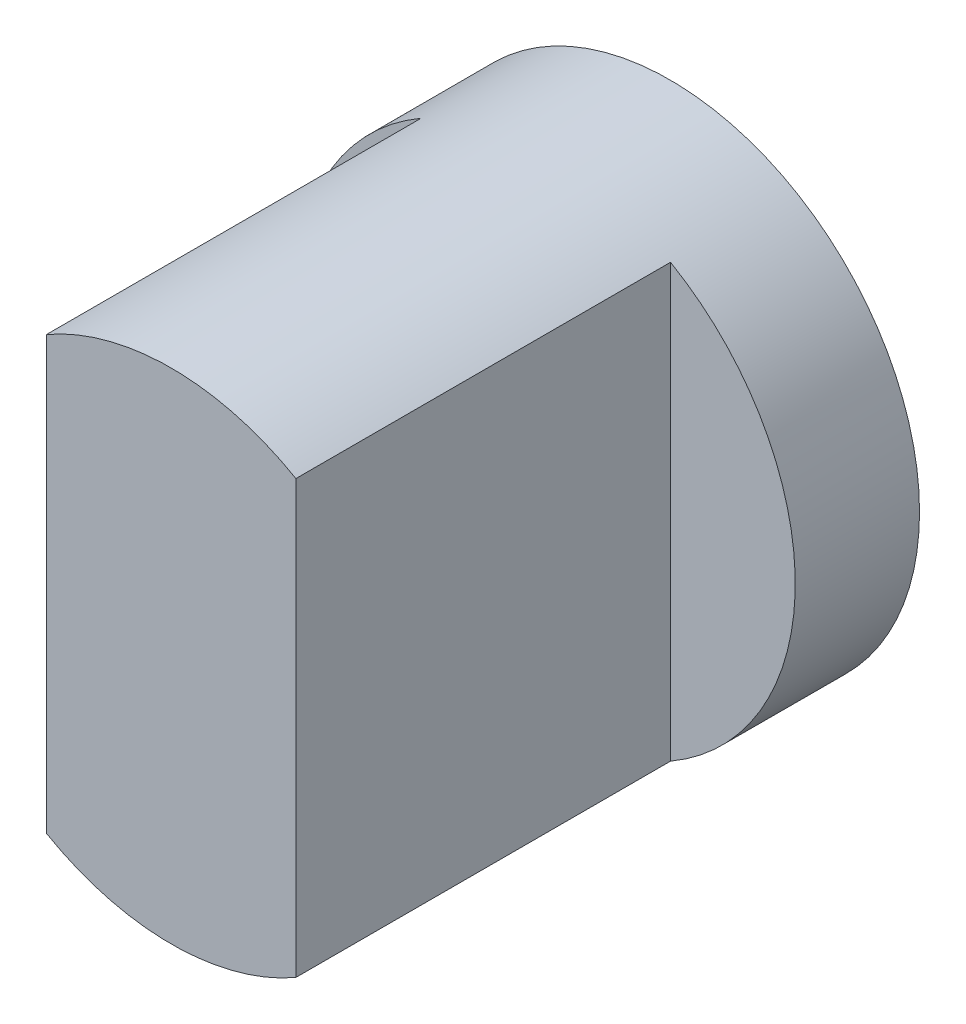
from build123d import *

# Parameters (mm, degrees)
SKETCH1_R           = 2
BOSS_EXTRUDE1_DEPTH = 4
CUT_EXTRUDE2_DEPTH  = 2


with BuildPart() as part:
    # Sketch1 → Boss-Extrude1 (new body)
    with BuildSketch(Plane.XY):
        Circle(SKETCH1_R)
    extrude(amount=BOSS_EXTRUDE1_DEPTH)

    # Sketch2 → Cut-Extrude2 (cut, symmetric)
    with BuildSketch(Plane(origin=(0, 0, 0), x_dir=(1, 0, 0), z_dir=(0, 1, 0))):
        Polygon((-1, -5), (1, -5), (2, -5), (2, -0.996424707), (1, -0.996424707), (1, -3), (1, -4), (-1, -4), (-1, -3), (-1, -0.996424707), (-2, -0.996424707), (-2, -5), align=None)
    extrude(amount=CUT_EXTRUDE2_DEPTH, both=True, mode=Mode.SUBTRACT)


solid = part.part
